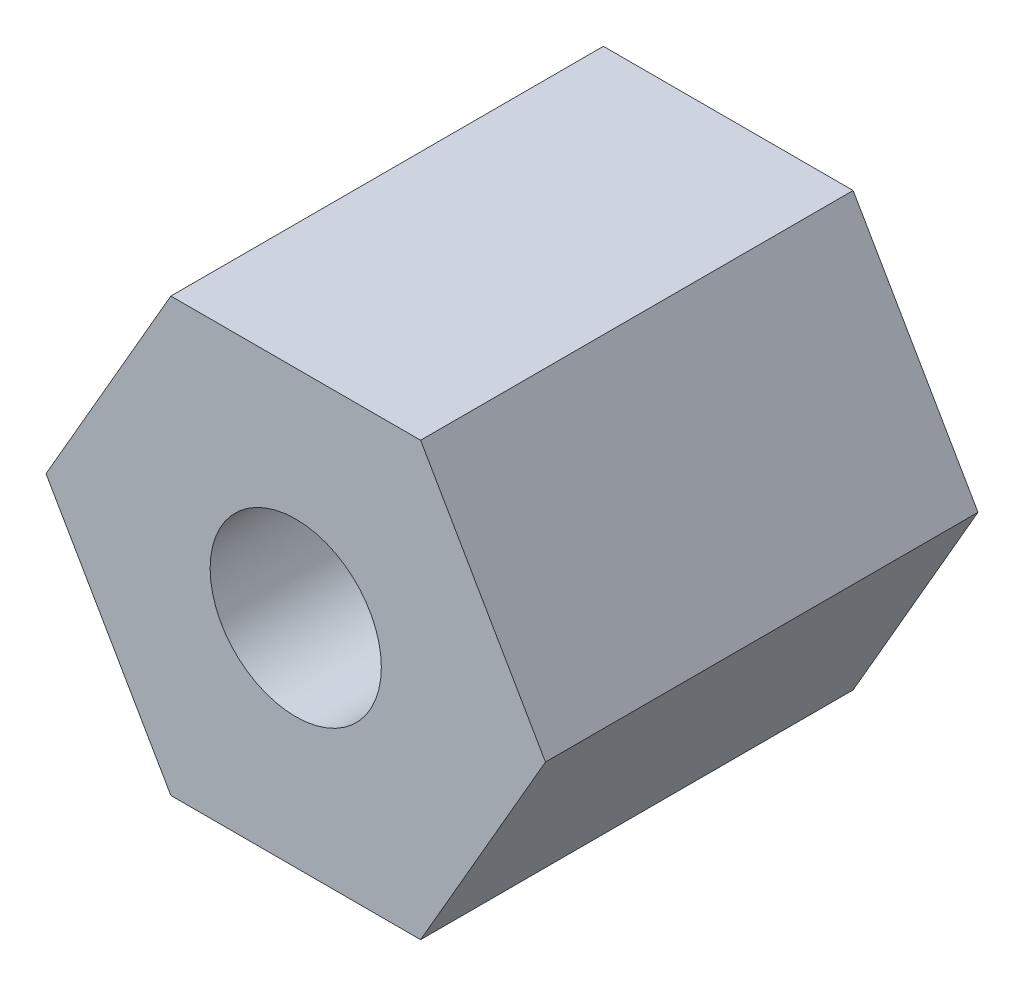
from build123d import *

# Parameters (mm, degrees)
BOSS_EXTRUDE1_DEPTH = 9.6
SKETCH3_R           = 1.9
CUT_EXTRUDE1_DEPTH  = 10.6


with BuildPart() as part:
    # Sketch2 → Boss-Extrude1 (new body)
    with BuildSketch(Plane.XY):
        Polygon((5.542562584, 0), (2.771281292, 4.8), (-2.771281292, 4.8), (-5.542562584, 0), (-2.771281292, -4.8), (2.771281292, -4.8), align=None)
    extrude(amount=BOSS_EXTRUDE1_DEPTH)

    # Sketch3 → Cut-Extrude1 (cut, through all)
    with BuildSketch(Plane(origin=(0, 0, 0), x_dir=(-1, 0, 0), z_dir=(0, 0, -1))):
        Circle(SKETCH3_R)
    extrude(amount=-CUT_EXTRUDE1_DEPTH, mode=Mode.SUBTRACT)


solid = part.part
